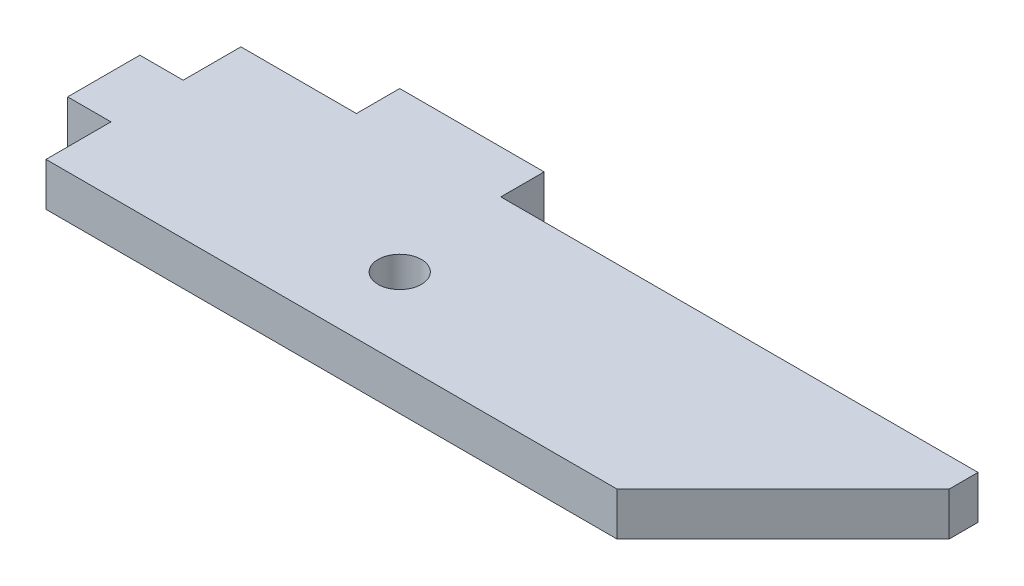
from build123d import *

# Parameters (mm, degrees)
SKETCH1_R           = 1.5
BOSS_EXTRUDE1_DEPTH = 3


with BuildPart() as part:
    # Sketch1 → Boss-Extrude1 (new body)
    with BuildSketch(Plane(origin=(0, 0, 0), x_dir=(1, 0, 0), z_dir=(0, 1, 0))):
        Polygon((-47.380002118, 7.413403038), (-47.380002118, 4.413403038), (-55.380002118, 4.413403038), (-55.380002118, 0.413403038), (-58.380002118, 0.413403038), (-58.380002118, -4.586596962), (-55.380002118, -4.586596962), (-55.380002118, -9.086596962), (-15.820002118, -9.086596962), (-4.330002118, 2.403403038), (-4.330002118, 4.413403038), (-37.380002118, 4.413403038), (-37.380002118, 7.413403038), align=None)
        with Locations((-36.380002118, -3.586596962)):
            Circle(SKETCH1_R, mode=Mode.SUBTRACT)
    extrude(amount=BOSS_EXTRUDE1_DEPTH)


solid = part.part
